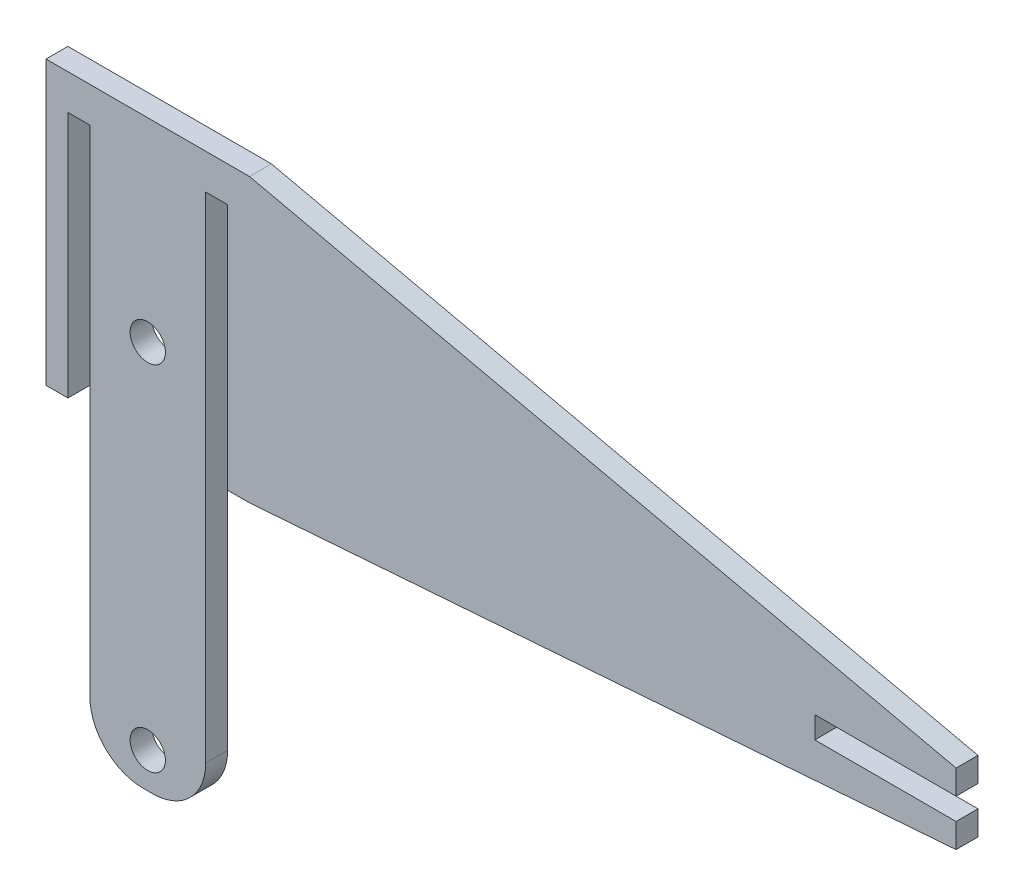
from build123d import *

# Parameters (mm, degrees)
SKETCH1_W           = 28.8
SKETCH1_H           = 40
BOSS_EXTRUDE1_DEPTH = 3.1
SKETCH2_R           = 2.5
SKETCH2_W           = 3.1
SKETCH2_H           = 35
CUT_EXTRUDE1_DEPTH  = 4.1
SKETCH3_W           = 16.4
SKETCH3_H           = 42.5
SKETCH3_R           = 2.5
BOSS_EXTRUDE2_DEPTH = 3.1
FILLET1_R           = 7.5
BOSS_EXTRUDE3_DEPTH = 3.1


with BuildPart() as part:
    # Sketch1 → Boss-Extrude1 (new body)
    with BuildSketch(Plane.XY):
        Rectangle(SKETCH1_W, SKETCH1_H)
    extrude(amount=BOSS_EXTRUDE1_DEPTH)

    # Sketch2 → Cut-Extrude1 (cut, through all)
    with BuildSketch(Plane.XY.offset(3.1)):
        with Locations((0, -7.5)):
            Circle(SKETCH2_R)
        with Locations((-9.75, -2.5)):
            Rectangle(SKETCH2_W, SKETCH2_H)
        with Locations((9.75, -2.5)):
            Rectangle(SKETCH2_W, SKETCH2_H)
    extrude(amount=-CUT_EXTRUDE1_DEPTH, mode=Mode.SUBTRACT)

    # Sketch3 → Boss-Extrude2 (add, through all)
    with BuildSketch(Plane.XY.offset(3.1)):
        with Locations((0, -41.25)):
            Rectangle(SKETCH3_W, SKETCH3_H)
        with Locations((0, -57.5)):
            Circle(SKETCH3_R, mode=Mode.SUBTRACT)
    extrude(amount=-BOSS_EXTRUDE2_DEPTH)

    # Fillet1
    fillet1_edges = [part.edges().sort_by_distance(p)[0] for p in [
        (-8.2, -62.5, 1.55),
        (8.2, -62.5, 1.55),
    ]]
    fillet(fillet1_edges, radius=FILLET1_R)

    # Sketch4 → Boss-Extrude3 (add, through all)
    with BuildSketch(Plane(origin=(0, 0, 0), x_dir=(-1, 0, 0), z_dir=(0, 0, -1))):
        Polygon((-14.4, 20), (-14.4, -20), (-114.4, -12.5), (-114.4, -9.05), (-94.4, -9.05), (-94.4, -5.95), (-114.4, -5.95), (-114.4, -2.5), align=None)
    extrude(amount=-BOSS_EXTRUDE3_DEPTH)


solid = part.part
